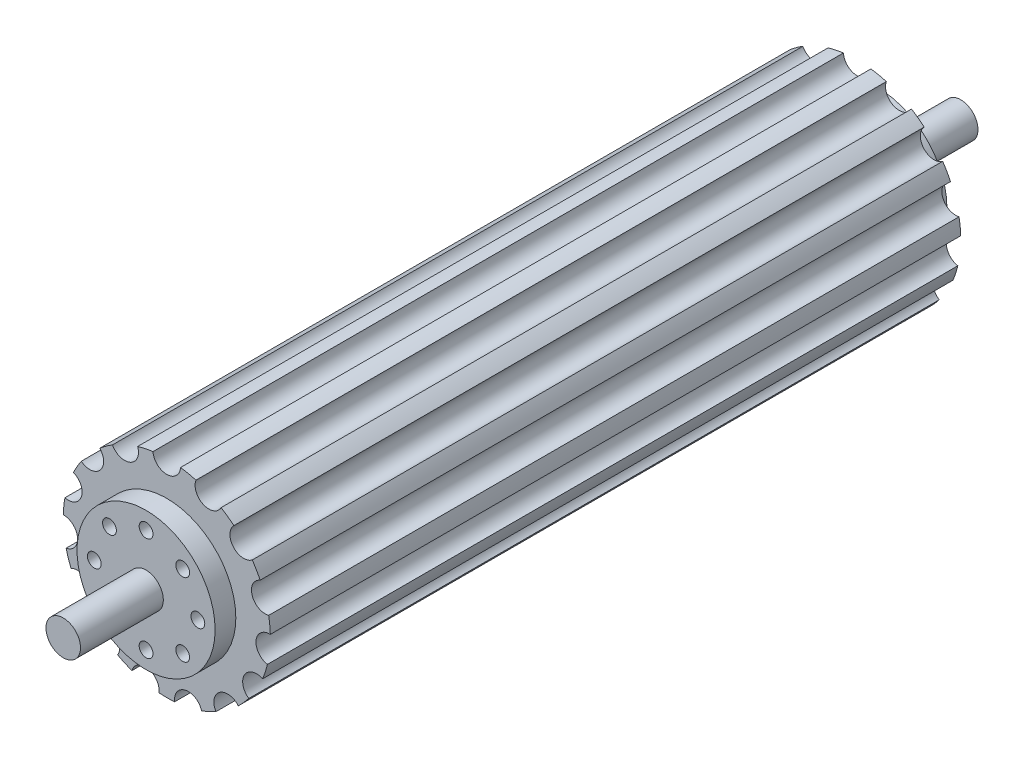
from build123d import *

# Parameters (mm, degrees)
SKETCH1_R           = 15
BOSS_EXTRUDE1_DEPTH = 100
SKETCH2_R           = 2.5
BOSS_EXTRUDE3_DEPTH = 15
SKETCH4_R           = 10
SKETCH4_R_2         = 2.5
BOSS_EXTRUDE4_DEPTH = 3
SKETCH7_R           = 1
CUT_EXTRUDE1_DEPTH  = 3
SKETCH8_R           = 2
CUT_EXTRUDE2_DEPTH  = 116


with BuildPart() as part:
    # Sketch1 → Boss-Extrude1 (new body)
    with BuildSketch(Plane.XY):
        Circle(SKETCH1_R)
    extrude(amount=BOSS_EXTRUDE1_DEPTH)

    # Sketch2 → Boss-Extrude3 (add)
    with BuildSketch(Plane.XY.offset(100)):
        Circle(SKETCH2_R)
    boss_extrude3 = extrude(amount=BOSS_EXTRUDE3_DEPTH)

    # Sketch4 → Boss-Extrude4 (add)
    with BuildSketch(Plane.XY.offset(100)):
        Circle(SKETCH4_R)
        Circle(SKETCH4_R_2, mode=Mode.SUBTRACT)
    boss_extrude4 = extrude(amount=BOSS_EXTRUDE4_DEPTH)

    # Mirror1: Boss-Extrude3, Boss-Extrude4 across plane
    add(boss_extrude3.mirror(Plane.XY.offset(50)))
    add(boss_extrude4.mirror(Plane.XY.offset(50)))

    # Sketch7 → Cut-Extrude1 (cut)
    with BuildSketch(Plane.XY.offset(103)):
        with Locations((0, 7.5)):
            Circle(SKETCH7_R)
        with Locations((5.303300859, 5.303300859)):
            Circle(SKETCH7_R)
        with Locations((7.5, 0)):
            Circle(SKETCH7_R)
        with Locations((5.303300859, -5.303300859)):
            Circle(SKETCH7_R)
        with Locations((0, -7.5)):
            Circle(SKETCH7_R)
        with Locations((-5.303300859, -5.303300859)):
            Circle(SKETCH7_R)
        with Locations((-7.5, 0)):
            Circle(SKETCH7_R)
        with Locations((-5.303300859, 5.303300859)):
            Circle(SKETCH7_R)
    extrude(amount=-CUT_EXTRUDE1_DEPTH, mode=Mode.SUBTRACT)

    # Sketch8 → Cut-Extrude2 (cut, through all)
    with BuildSketch(Plane.XY.offset(100)):
        with Locations((0, 15)):
            Circle(SKETCH8_R)
        with Locations((6.101049646, 13.703181865)):
            Circle(SKETCH8_R)
        with Locations((11.147172382, 10.036959095)):
            Circle(SKETCH8_R)
        with Locations((14.265847744, 4.635254916)):
            Circle(SKETCH8_R)
        with Locations((14.917828431, -1.567926949)):
            Circle(SKETCH8_R)
        with Locations((12.990381057, -7.5)):
            Circle(SKETCH8_R)
        with Locations((8.816778784, -12.135254916)):
            Circle(SKETCH8_R)
        with Locations((3.118675362, -14.672214011)):
            Circle(SKETCH8_R)
        with Locations((-3.118675362, -14.672214011)):
            Circle(SKETCH8_R)
        with Locations((-8.816778784, -12.135254916)):
            Circle(SKETCH8_R)
        with Locations((-12.990381057, -7.5)):
            Circle(SKETCH8_R)
        with Locations((-14.917828431, -1.567926949)):
            Circle(SKETCH8_R)
        with Locations((-14.265847744, 4.635254916)):
            Circle(SKETCH8_R)
        with Locations((-11.147172382, 10.036959095)):
            Circle(SKETCH8_R)
        with Locations((-6.101049646, 13.703181865)):
            Circle(SKETCH8_R)
    extrude(amount=-CUT_EXTRUDE2_DEPTH, mode=Mode.SUBTRACT)


solid = part.part
